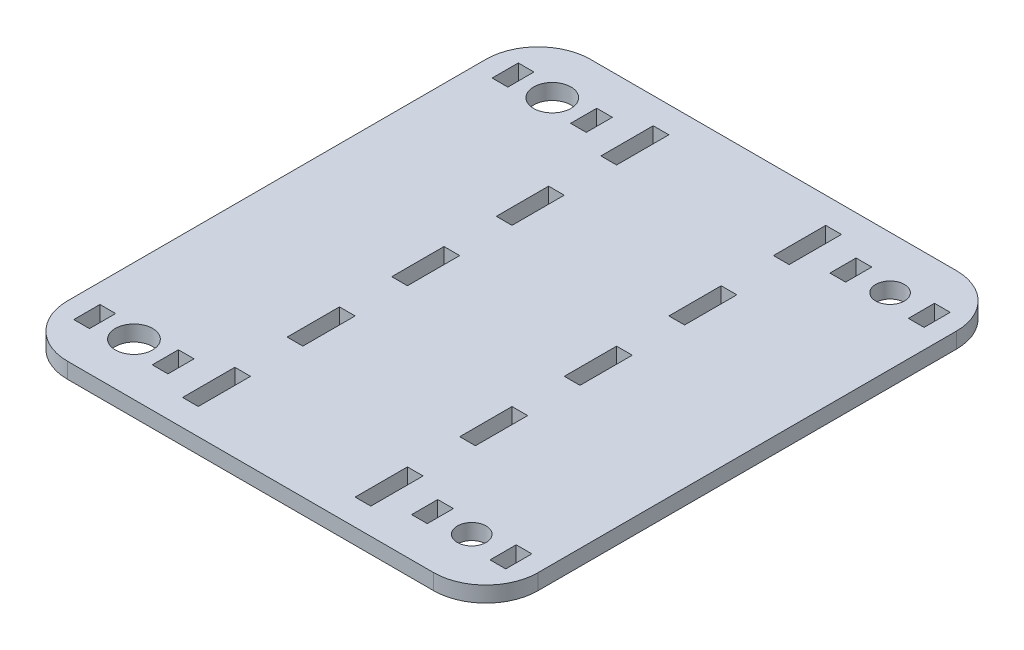
from build123d import *

# Parameters (mm, degrees)
SKETCH2_W           = 90
SKETCH2_H           = 100
SKETCH2_R           = 3.5685
SKETCH2_R_2         = 2.75
SKETCH2_W_2         = 3
SKETCH2_H_2         = 5
SKETCH2_H_3         = 10
BOSS_EXTRUDE1_DEPTH = 3
FILLET1_R           = 10


with BuildPart() as part:
    # Sketch2 → Boss-Extrude1 (new body)
    with BuildSketch(Plane(origin=(0, 0, 0), x_dir=(1, 0, 0), z_dir=(0, 1, 0))):
        Rectangle(SKETCH2_W, SKETCH2_H)
        with Locations((-32.3, 40)):
            Circle(SKETCH2_R, mode=Mode.SUBTRACT)
        with Locations((-32.3, -40)):
            Circle(SKETCH2_R, mode=Mode.SUBTRACT)
        with Locations((32.3, 40)):
            Circle(SKETCH2_R_2, mode=Mode.SUBTRACT)
        with Locations((32.3, -40)):
            Circle(SKETCH2_R_2, mode=Mode.SUBTRACT)
        with Locations((39.8, 40)):
            Rectangle(SKETCH2_W_2, SKETCH2_H_2, mode=Mode.SUBTRACT)
        with Locations((-16.5, 20)):
            Rectangle(SKETCH2_W_2, SKETCH2_H_3, mode=Mode.SUBTRACT)
        with Locations((-16.5, 0)):
            Rectangle(SKETCH2_W_2, SKETCH2_H_3, mode=Mode.SUBTRACT)
        with Locations((-16.5, 40)):
            Rectangle(SKETCH2_W_2, SKETCH2_H_3, mode=Mode.SUBTRACT)
        with Locations((-16.5, -20)):
            Rectangle(SKETCH2_W_2, SKETCH2_H_3, mode=Mode.SUBTRACT)
        with Locations((-16.5, -40)):
            Rectangle(SKETCH2_W_2, SKETCH2_H_3, mode=Mode.SUBTRACT)
        with Locations((16.5, -40)):
            Rectangle(SKETCH2_W_2, SKETCH2_H_3, mode=Mode.SUBTRACT)
        with Locations((16.5, -20)):
            Rectangle(SKETCH2_W_2, SKETCH2_H_3, mode=Mode.SUBTRACT)
        with Locations((16.5, 40)):
            Rectangle(SKETCH2_W_2, SKETCH2_H_3, mode=Mode.SUBTRACT)
        with Locations((16.5, 20)):
            Rectangle(SKETCH2_W_2, SKETCH2_H_3, mode=Mode.SUBTRACT)
        with Locations((16.5, 0)):
            Rectangle(SKETCH2_W_2, SKETCH2_H_3, mode=Mode.SUBTRACT)
        with Locations((-39.8, 40)):
            Rectangle(SKETCH2_W_2, SKETCH2_H_2, mode=Mode.SUBTRACT)
        with Locations((39.8, -40)):
            Rectangle(SKETCH2_W_2, SKETCH2_H_2, mode=Mode.SUBTRACT)
        with Locations((-39.8, -40)):
            Rectangle(SKETCH2_W_2, SKETCH2_H_2, mode=Mode.SUBTRACT)
        with Locations((-24.8, -40)):
            Rectangle(SKETCH2_W_2, SKETCH2_H_2, mode=Mode.SUBTRACT)
        with Locations((-24.8, 40)):
            Rectangle(SKETCH2_W_2, SKETCH2_H_2, mode=Mode.SUBTRACT)
        with Locations((24.8, 40)):
            Rectangle(SKETCH2_W_2, SKETCH2_H_2, mode=Mode.SUBTRACT)
        with Locations((24.8, -40)):
            Rectangle(SKETCH2_W_2, SKETCH2_H_2, mode=Mode.SUBTRACT)
    extrude(amount=BOSS_EXTRUDE1_DEPTH)

    # Fillet1
    fillet1_edges = [part.edges().sort_by_distance(p)[0] for p in [
        (-45, 1.5, -50),
        (45, 1.5, -50),
        (45, 1.5, 50),
        (-45, 1.5, 50),
    ]]
    fillet(fillet1_edges, radius=FILLET1_R)


solid = part.part
